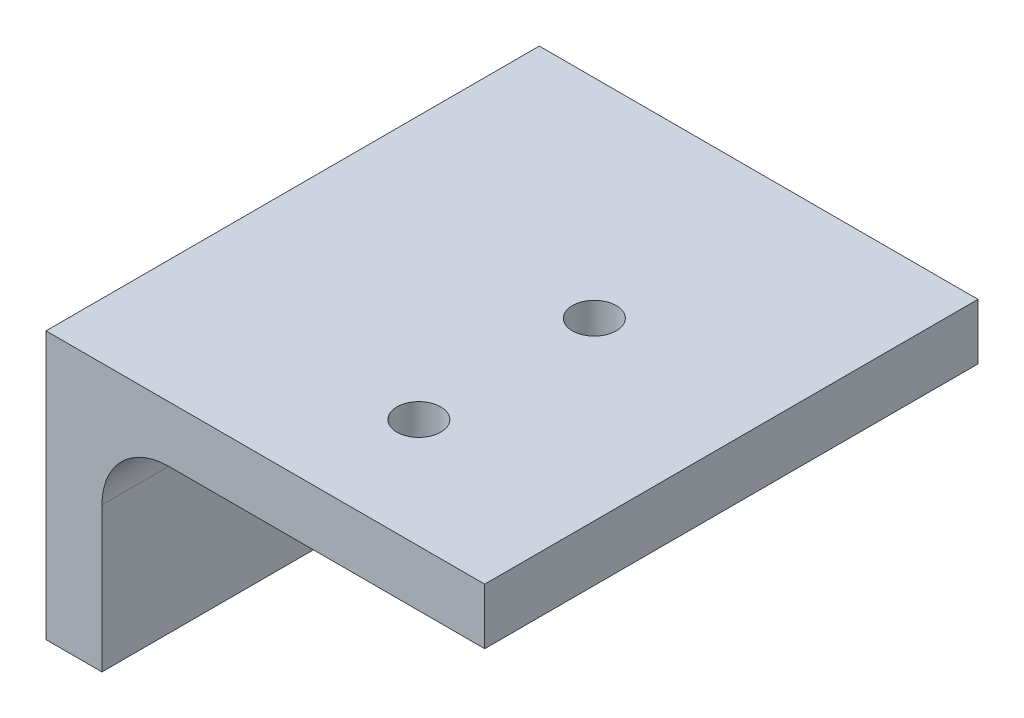
from build123d import *

# Parameters (mm, degrees)
BOSS_EXTRUDE1_DEPTH = 56.22
SKETCH2_R           = 2.5
CUT_EXTRUDE1_DEPTH  = 31.48
SKETCH4_R           = 2.5
CUT_EXTRUDE2_DEPTH  = 51


with BuildPart() as part:
    # Sketch1 → Boss-Extrude1 (new body)
    with BuildSketch(Plane.XY):
        with BuildLine():
            Line((45.33, -9.4), (45.33, -39.88))
            Line((45.33, -39.88), (51.7054, -39.88))
            Line((51.7054, -39.88), (51.7054, -23.3954))
            ThreePointArc((51.7054, -23.3954), (53.937246327, -18.007246327), (59.3254, -15.7754))
            Line((59.3254, -15.7754), (95.33, -15.7754))
            Line((95.33, -15.7754), (95.33, -9.4))
            Line((95.33, -9.4), (45.33, -9.4))
        make_face()
    extrude(amount=-BOSS_EXTRUDE1_DEPTH)

    # Sketch2 → Cut-Extrude1 (cut, through all)
    with BuildSketch(Plane(origin=(0, -9.4, 0), x_dir=(1, 0, 0), z_dir=(0, 1, 0))):
        with Locations((75.33, 12.493588432)):
            Circle(SKETCH2_R)
        with Locations((75.33, 32.493588432)):
            Circle(SKETCH2_R)
    extrude(amount=-CUT_EXTRUDE1_DEPTH, mode=Mode.SUBTRACT)

    # Sketch4 → Cut-Extrude2 (cut, through all)
    with BuildSketch(Plane.ZY.offset(-45.33)):
        with Locations((-32.598, -27.18)):
            Circle(SKETCH4_R)
    extrude(amount=-CUT_EXTRUDE2_DEPTH, mode=Mode.SUBTRACT)


solid = part.part
